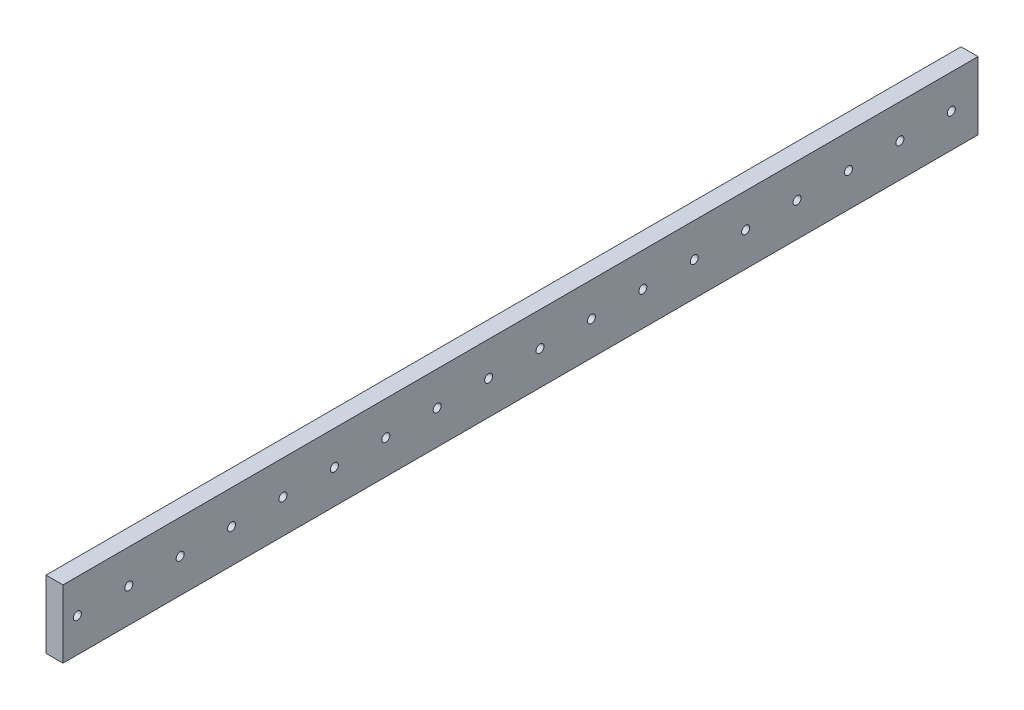
from build123d import *

# Parameters (mm, degrees)
CROQUIS2_W              = 12.7
CROQUIS2_H              = 50.8
SALIENTE_EXTRUIR1_DEPTH = 685.3
CROQUIS3_R              = 3
CORTAR_EXTRUIR1_DEPTH   = 13.7


with BuildPart() as part:
    # Croquis2 → Saliente-Extruir1 (new body)
    with BuildSketch(Plane.XY):
        Rectangle(CROQUIS2_W, CROQUIS2_H)
    extrude(amount=-SALIENTE_EXTRUIR1_DEPTH)

    # Croquis3 → Cortar-Extruir1 (cut, through all)
    with BuildSketch(Plane.ZY.offset(6.35)):
        with Locations((-665.3, 0)):
            Circle(CROQUIS3_R)
        with Locations((-626.8, 0)):
            Circle(CROQUIS3_R)
        with Locations((-588.3, 0)):
            Circle(CROQUIS3_R)
        with Locations((-549.8, 0)):
            Circle(CROQUIS3_R)
        with Locations((-511.3, 0)):
            Circle(CROQUIS3_R)
        with Locations((-472.8, 0)):
            Circle(CROQUIS3_R)
        with Locations((-434.3, 0)):
            Circle(CROQUIS3_R)
        with Locations((-395.8, 0)):
            Circle(CROQUIS3_R)
        with Locations((-357.3, 0)):
            Circle(CROQUIS3_R)
        with Locations((-318.8, 0)):
            Circle(CROQUIS3_R)
        with Locations((-280.3, 0)):
            Circle(CROQUIS3_R)
        with Locations((-241.8, 0)):
            Circle(CROQUIS3_R)
        with Locations((-203.3, 0)):
            Circle(CROQUIS3_R)
        with Locations((-164.8, 0)):
            Circle(CROQUIS3_R)
        with Locations((-126.3, 0)):
            Circle(CROQUIS3_R)
        with Locations((-87.8, 0)):
            Circle(CROQUIS3_R)
        with Locations((-49.3, 0)):
            Circle(CROQUIS3_R)
        with Locations((-10.8, 0)):
            Circle(CROQUIS3_R)
    extrude(amount=-CORTAR_EXTRUIR1_DEPTH, mode=Mode.SUBTRACT)


solid = part.part
